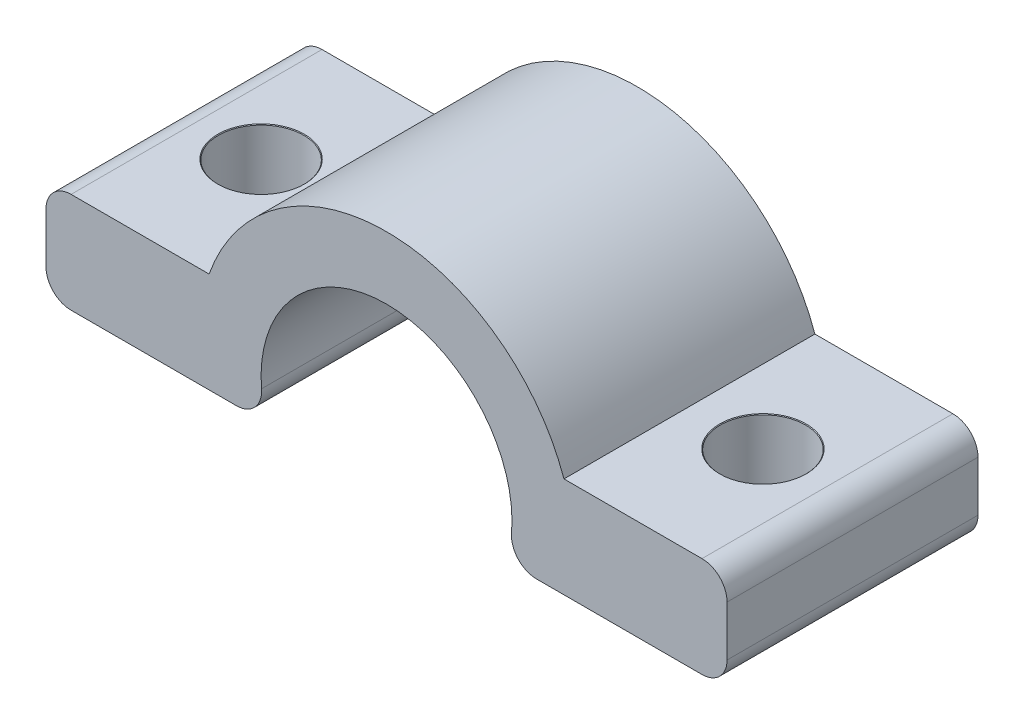
from build123d import *

# Parameters (mm, degrees)
BOSS_EXTRUDE1_DEPTH            = 10
M3_CLEARANCE_HOLE1_D           = 3.4
M3_CLEARANCE_HOLE1_CSINK_D     = 3.45
M3_CLEARANCE_HOLE1_CSINK_ANGLE = 90
FILLET1_R                      = 1


with BuildPart() as part:
    # Sketch2 → Boss-Extrude1 (new body)
    with BuildSketch(Plane.XY):
        with BuildLine():
            Line((4.769696007, -1.5), (13.571067812, -1.5))
            Line((13.571067812, -1.5), (13.571067812, 2.5))
            Line((13.571067812, 2.5), (7.071067812, 2.5))
            ThreePointArc((7.071067812, 2.5), (0, 7.5), (-7.071067812, 2.5))
            Line((-7.071067812, 2.5), (-13.571067812, 2.5))
            Line((-13.571067812, 2.5), (-13.571067812, -1.5))
            Line((-13.571067812, -1.5), (-4.769696007, -1.5))
            ThreePointArc((-4.769696007, -1.5), (0, 5), (4.769696007, -1.5))
        make_face()
    extrude(amount=BOSS_EXTRUDE1_DEPTH)

    # M3 Clearance Hole1 (through all)
    with Locations(Plane(origin=(0, 2.5, 0), x_dir=(1, 0, 0), z_dir=(0, 1, 0))):
        with Locations((-10, -5), (10, -5)):
            CounterSinkHole(M3_CLEARANCE_HOLE1_D / 2, M3_CLEARANCE_HOLE1_CSINK_D / 2, counter_sink_angle=M3_CLEARANCE_HOLE1_CSINK_ANGLE)

    # Fillet1
    fillet1_edges = [part.edges().sort_by_distance(p)[0] for p in [
        (13.571067812, 2.5, 5),
        (13.571067812, -1.5, 5),
        (4.769696007, -1.5, 5),
        (-4.769696007, -1.5, 5),
        (-13.571067812, -1.5, 5),
        (-13.571067812, 2.5, 5),
    ]]
    fillet(fillet1_edges, radius=FILLET1_R)


solid = part.part
